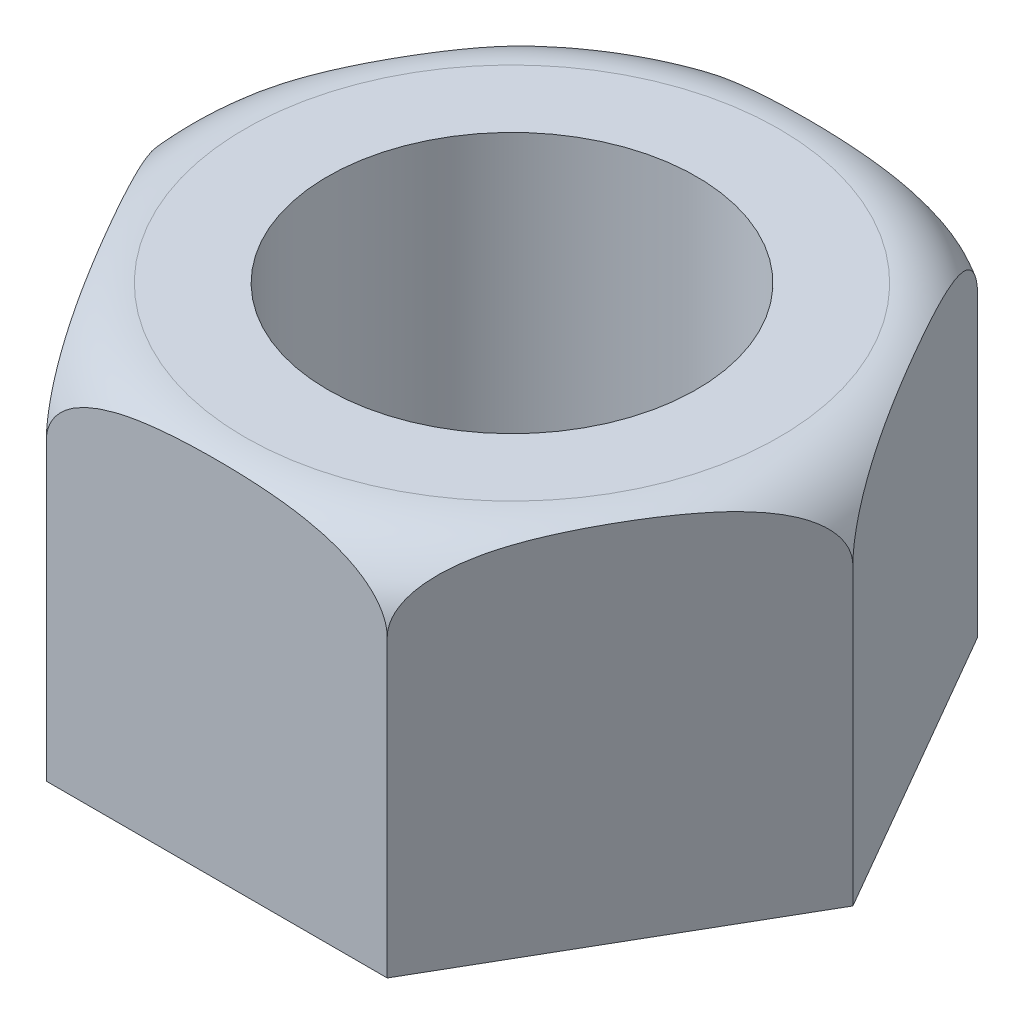
from build123d import *

# Parameters (mm, degrees)
SKETCH1_R           = 5
BOSS_EXTRUDE1_DEPTH = 10


with BuildPart() as part:
    # Sketch1 → Boss-Extrude1 (new body)
    with BuildSketch(Plane(origin=(0, 0, 0), x_dir=(1, 0, 0), z_dir=(0, 1, 0))):
        Polygon((9.237604307, 0), (4.618802154, 8), (-4.618802154, 8), (-9.237604307, 0), (-4.618802154, -8), (4.618802154, -8), align=None)
        Circle(SKETCH1_R, mode=Mode.SUBTRACT)
    extrude(amount=BOSS_EXTRUDE1_DEPTH)

    # Sketch2 → Cut-Revolve1 (revolve, cut)
    with BuildSketch(Plane.XY):
        with BuildLine():
            Line((9.237604307, 10), (7.237604307, 10))
            ThreePointArc((7.237604307, 10), (8.651817869, 9.414213562), (9.237604307, 8))
            Line((9.237604307, 8), (9.237604307, 10))
        make_face()
    revolve(axis=Axis((0, 0, 0), (0, 1, 0)), mode=Mode.SUBTRACT)


solid = part.part
